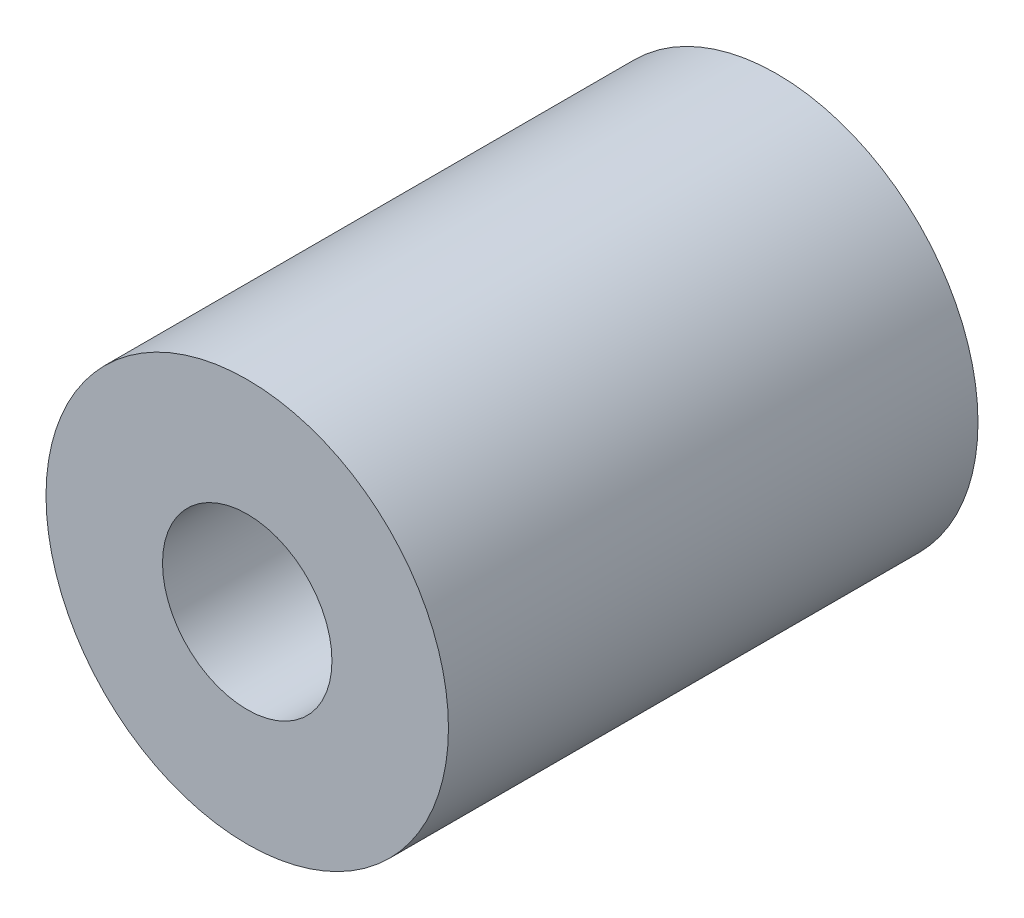
from build123d import *

# Parameters (mm, degrees)
SKETCH1_R           = 9.5
SKETCH1_R_2         = 4
BOSS_EXTRUDE1_DEPTH = 25


with BuildPart() as part:
    # Sketch1 → Boss-Extrude1 (new body)
    with BuildSketch(Plane.XY):
        Circle(SKETCH1_R)
        Circle(SKETCH1_R_2, mode=Mode.SUBTRACT)
    extrude(amount=BOSS_EXTRUDE1_DEPTH)


solid = part.part
